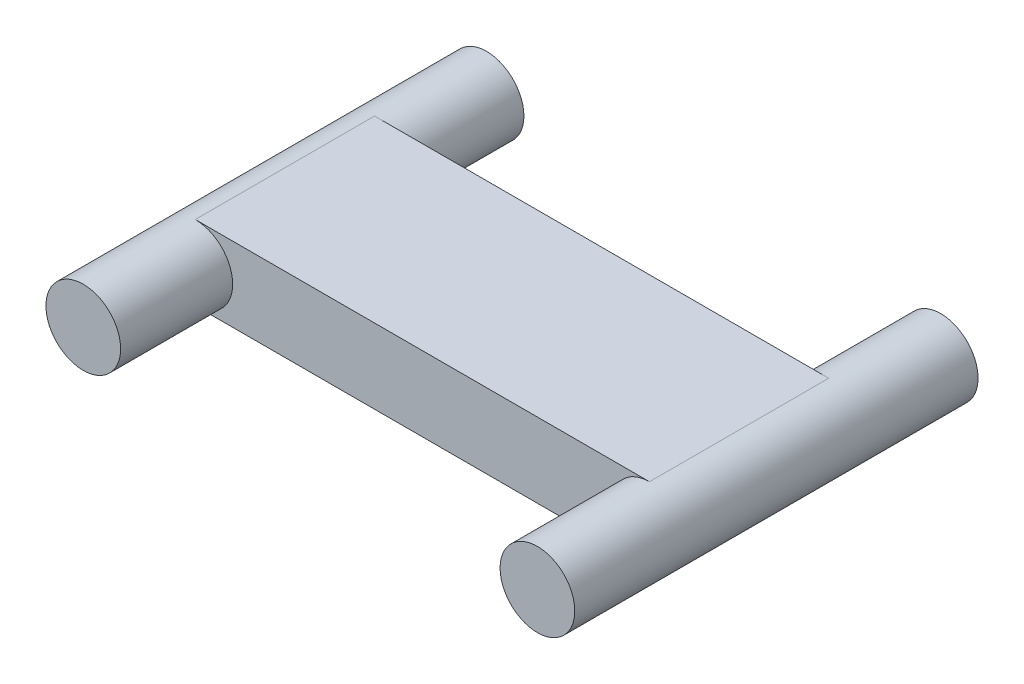
from build123d import *
from build123d.topology import SkipClean

# Parameters (mm, degrees)
BOSS_EXTRUDE1_DEPTH     = 3.81
SKETCH2_R               = 1.5875
BOSS_EXTRUDE2_DEPTH     = 4.7625
MIRROR2_COPY_1_SKETCH_R = 1.5875
MIRROR2_COPY_1_DEPTH    = 4.7625


with BuildPart() as part:
    # Sketch1 → Boss-Extrude1 (new body, symmetric)
    with BuildSketch(Plane.XY):
        with BuildLine():
            Line((9.65327, 1.5875), (-9.65327, 1.5875))
            ThreePointArc((-9.65327, 1.5875), (-11.24077, 0), (-9.65327, -1.5875))
            Line((-9.65327, -1.5875), (9.65327, -1.5875))
            ThreePointArc((9.65327, -1.5875), (11.24077, 0), (9.65327, 1.5875))
        make_face()
    extrude(amount=BOSS_EXTRUDE1_DEPTH, both=True)

    # Sketch2 → Boss-Extrude2 (add)
    with SkipClean():  # keep this step's faces unmerged: merging them makes the solid invalid here
        with BuildSketch(Plane.XY.offset(3.81)):
            with Locations(Location((-9.65327, 0, 0), (0, 0, 270))):  # turned: the seam where the file's is
                Circle(SKETCH2_R)
        boss_extrude2 = extrude(amount=BOSS_EXTRUDE2_DEPTH)

    # Mirror1: Boss-Extrude2 across plane
    with SkipClean():  # keep this step's faces unmerged: merging them makes the solid invalid here
        add(boss_extrude2.mirror(Plane(origin=(0, 0, 0), x_dir=(0, 0, 1), z_dir=(1, 0, 0))))

    # Mirror2: Boss-Extrude2 across plane
    with SkipClean():  # keep this step's faces unmerged: merging them makes the solid invalid here
        add(boss_extrude2.mirror(Plane.XY))

    # Mirror2 copy 1 sketch → Mirror2 copy 1 (add)
    with SkipClean():  # keep this step's faces unmerged: merging them makes the solid invalid here
        with BuildSketch(Plane(origin=(0, 0, -3.81), x_dir=(-1, 0, 0), z_dir=(0, 0, -1))):
            with Locations(Location((-9.65327, 0, 0), (0, 0, 270))):  # turned: the seam where the file's is
                Circle(MIRROR2_COPY_1_SKETCH_R)
        extrude(amount=MIRROR2_COPY_1_DEPTH)


solid = part.part
